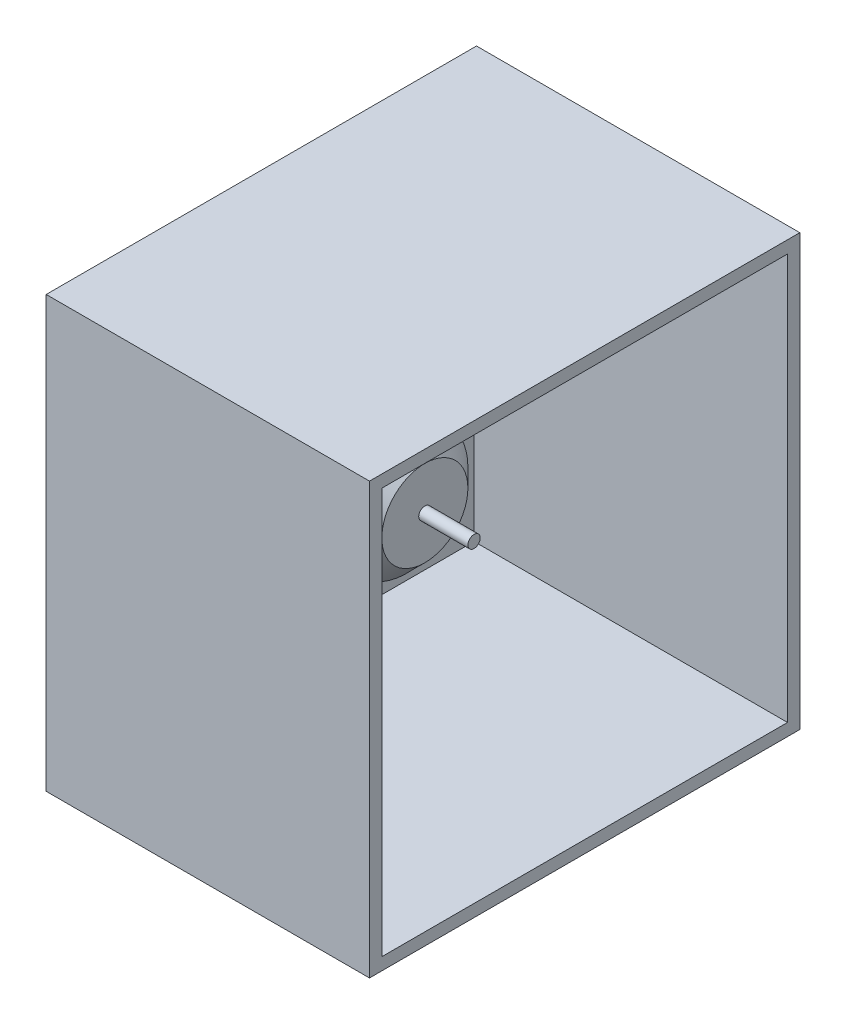
from build123d import *

# Parameters (mm, degrees)
SKETCH1_R           = 12.7
BOSS_EXTRUDE1_DEPTH = 15.24
CHAMFER1_SIZE       = 3.81
CHAMFER3_SIZE       = 5.08
CHAMFER3_SIZE2      = 2.932939367
SKETCH2_R           = 1.27
BOSS_EXTRUDE3_DEPTH = 10.16
SKETCH3_R           = 0.639919682
SKETCH3_R_2         = 0.635
BOSS_EXTRUDE5_DEPTH = 1.27
SKETCH4_W           = 88.9
SKETCH4_H           = 88.9
BOSS_EXTRUDE6_DEPTH = 2.032
SKETCH5_R           = 3.81
CUT_EXTRUDE2_DEPTH  = 44.942
BOSS_EXTRUDE7_DEPTH = 1.27
SKETCH8_R           = 0.635
SKETCH8_R_2         = 0.639919682
CUT_EXTRUDE3_DEPTH  = 1.27
SKETCH9_W           = 88.9
SKETCH9_H           = 88.9
SKETCH9_W_2         = 83.82
SKETCH9_H_2         = 83.82
BOSS_EXTRUDE8_DEPTH = 80
SKETCH11_W          = 15.24
SKETCH11_H          = 88.9
CUT_EXTRUDE4_DEPTH  = 89.9


with BuildPart() as part:
    # Sketch1 → Boss-Extrude1 (new body, symmetric)
    with BuildSketch(Plane(origin=(0, 0, 0), x_dir=(0, 0, -1), z_dir=(1, 0, 0))):
        Circle(SKETCH1_R)
    extrude(amount=BOSS_EXTRUDE1_DEPTH, both=True)

    # Chamfer1
    chamfer1_edges = [part.edges().sort_by_distance(p)[0] for p in [
        (15.24, 0, 12.7),
    ]]
    chamfer(chamfer1_edges, length=CHAMFER1_SIZE)

    # Chamfer3
    chamfer3_edges = [part.edges().sort_by_distance(p)[0] for p in [
        (-15.24, 0, 12.7),
    ]]
    chamfer3_side = [part.faces().sort_by_distance(p)[0] for p in [
        (-15.24, 0, 0),
    ]]
    chamfer(chamfer3_edges, length=CHAMFER3_SIZE, length2=CHAMFER3_SIZE2, reference=chamfer3_side[0])

    # Sketch2 → Boss-Extrude3 (add)
    with BuildSketch(Plane(origin=(15.24, 0, 0), x_dir=(0, 0, -1), z_dir=(1, 0, 0))):
        Circle(SKETCH2_R)
    extrude(amount=BOSS_EXTRUDE3_DEPTH)

    # Sketch3 → Boss-Extrude5 (add)
    with BuildSketch(Plane.ZY.offset(15.24)):
        with BuildLine():
            Line((-5.715, -1.905), (-17.78, -1.905))
            ThreePointArc((-17.78, -1.905), (-18.678025612, -1.533025612), (-19.05, -0.635))
            Line((-19.05, -0.635), (-19.05, 0.635))
            ThreePointArc((-19.05, 0.635), (-18.678025612, 1.533025612), (-17.78, 1.905))
            Line((-17.78, 1.905), (-5.715, 1.905))
            ThreePointArc((-5.715, 1.905), (-3.020923164, 3.020923164), (-1.905, 5.715))
            Line((-1.905, 5.715), (-1.905, 17.78))
            ThreePointArc((-1.905, 17.78), (-1.533025612, 18.678025612), (-0.635, 19.05))
            Line((-0.635, 19.05), (0.635, 19.05))
            ThreePointArc((0.635, 19.05), (1.533025612, 18.678025612), (1.905, 17.78))
            Line((1.905, 17.78), (1.905, 5.715))
            ThreePointArc((1.905, 5.715), (3.020923164, 3.020923164), (5.715, 1.905))
            Line((5.715, 1.905), (17.78, 1.905))
            ThreePointArc((17.78, 1.905), (18.678025612, 1.533025612), (19.05, 0.635))
            Line((19.05, 0.635), (19.05, -0.635))
            ThreePointArc((19.05, -0.635), (18.678025612, -1.533025612), (17.78, -1.905))
            Line((17.78, -1.905), (5.715, -1.905))
            ThreePointArc((5.715, -1.905), (3.020923164, -3.020923164), (1.905, -5.715))
            Line((1.905, -5.715), (1.905, -17.78))
            ThreePointArc((1.905, -17.78), (1.533025612, -18.678025612), (0.635, -19.05))
            Line((0.635, -19.05), (-0.635, -19.05))
            ThreePointArc((-0.635, -19.05), (-1.533025612, -18.678025612), (-1.905, -17.78))
            Line((-1.905, -17.78), (-1.905, -5.715))
            ThreePointArc((-1.905, -5.715), (-3.020923164, -3.020923164), (-5.715, -1.905))
        make_face()
        with Locations((0, -17.78)):
            Circle(SKETCH3_R, mode=Mode.SUBTRACT)
        with Locations((17.78, 0)):
            Circle(SKETCH3_R_2, mode=Mode.SUBTRACT)
        with Locations((0, 17.78)):
            Circle(SKETCH3_R_2, mode=Mode.SUBTRACT)
        with Locations((-17.78, 0)):
            Circle(SKETCH3_R_2, mode=Mode.SUBTRACT)
    extrude(amount=BOSS_EXTRUDE5_DEPTH)

    # Sketch4 → Boss-Extrude6 (add)
    with BuildSketch(Plane.ZY.offset(16.51)):
        Rectangle(SKETCH4_W, SKETCH4_H)
    extrude(amount=BOSS_EXTRUDE6_DEPTH)

    # Sketch5 → Cut-Extrude2 (cut, through all)
    with BuildSketch(Plane.ZY.offset(18.542)):
        with Locations((0, 29.21)):
            Circle(SKETCH5_R)
        with Locations((20.654589078, 20.654589078)):
            Circle(SKETCH5_R)
        with Locations((29.21, 0)):
            Circle(SKETCH5_R)
        with Locations((20.654589078, -20.654589078)):
            Circle(SKETCH5_R)
        with Locations((0, -29.21)):
            Circle(SKETCH5_R)
        with Locations((-20.654589078, -20.654589078)):
            Circle(SKETCH5_R)
        with Locations((-29.21, 0)):
            Circle(SKETCH5_R)
        with Locations((-20.654589078, 20.654589078)):
            Circle(SKETCH5_R)
    extrude(amount=-CUT_EXTRUDE2_DEPTH, mode=Mode.SUBTRACT)

    # Sketch7 → Boss-Extrude7 (add)
    with BuildSketch(Plane.ZY.offset(18.542)):
        with BuildLine():
            Line((1.905, 5.715), (1.905, 7.378033275))
            Line((1.905, 7.378033275), (1.905, 17.78))
            ThreePointArc((1.905, 17.78), (1.533025612, 18.678025612), (0.635, 19.05))
            Line((0.635, 19.05), (-0.635, 19.05))
            ThreePointArc((-0.635, 19.05), (-1.533025612, 18.678025612), (-1.905, 17.78))
            Line((-1.905, 17.78), (-1.905, 5.715))
            ThreePointArc((-1.905, 5.715), (-3.020923164, 3.020923164), (-5.715, 1.905))
            Line((-5.715, 1.905), (-7.378033275, 1.905))
            Line((-7.378033275, 1.905), (-17.78, 1.905))
            ThreePointArc((-17.78, 1.905), (-18.678025612, 1.533025612), (-19.05, 0.635))
            Line((-19.05, 0.635), (-19.05, -0.635))
            ThreePointArc((-19.05, -0.635), (-18.678025612, -1.533025612), (-17.78, -1.905))
            Line((-17.78, -1.905), (-7.378033275, -1.905))
            Line((-7.378033275, -1.905), (-5.715, -1.905))
            ThreePointArc((-5.715, -1.905), (-3.020923164, -3.020923164), (-1.905, -5.715))
            Line((-1.905, -5.715), (-1.905, -7.378033275))
            Line((-1.905, -7.378033275), (-1.905, -17.78))
            ThreePointArc((-1.905, -17.78), (-1.533025612, -18.678025612), (-0.635, -19.05))
            Line((-0.635, -19.05), (0.635, -19.05))
            ThreePointArc((0.635, -19.05), (1.533025612, -18.678025612), (1.905, -17.78))
            Line((1.905, -17.78), (1.905, -7.378033275))
            Line((1.905, -7.378033275), (1.905, -5.715))
            ThreePointArc((1.905, -5.715), (3.020923164, -3.020923164), (5.715, -1.905))
            Line((5.715, -1.905), (7.378033275, -1.905))
            Line((7.378033275, -1.905), (17.78, -1.905))
            ThreePointArc((17.78, -1.905), (18.678025612, -1.533025612), (19.05, -0.635))
            Line((19.05, -0.635), (19.05, 0.635))
            ThreePointArc((19.05, 0.635), (18.678025612, 1.533025612), (17.78, 1.905))
            Line((17.78, 1.905), (7.378033275, 1.905))
            Line((7.378033275, 1.905), (5.715, 1.905))
            ThreePointArc((5.715, 1.905), (3.020923164, 3.020923164), (1.905, 5.715))
        make_face()
    extrude(amount=BOSS_EXTRUDE7_DEPTH)

    # Sketch8 → Cut-Extrude3 (cut)
    with BuildSketch(Plane.ZY.offset(19.812)):
        with Locations((0, 17.78)):
            Circle(SKETCH8_R)
        with Locations((17.78, 0)):
            Circle(SKETCH8_R)
        with Locations((0, -17.78)):
            Circle(SKETCH8_R_2)
        with Locations((-17.78, 0)):
            Circle(SKETCH8_R)
    extrude(amount=-CUT_EXTRUDE3_DEPTH, mode=Mode.SUBTRACT)

    # Sketch9 → Boss-Extrude8 (add)
    with BuildSketch(Plane(origin=(-16.51, 0, 0), x_dir=(0, 0, -1), z_dir=(1, 0, 0))):
        Rectangle(SKETCH9_W, SKETCH9_H)
        Rectangle(SKETCH9_W_2, SKETCH9_H_2, mode=Mode.SUBTRACT)
    extrude(amount=BOSS_EXTRUDE8_DEPTH)

    # Sketch11 → Cut-Extrude4 (cut, through all)
    with BuildSketch(Plane.XY.offset(44.45)):
        with Locations((55.87, 0)):
            Rectangle(SKETCH11_W, SKETCH11_H)
    extrude(amount=-CUT_EXTRUDE4_DEPTH, mode=Mode.SUBTRACT)


solid = part.part
